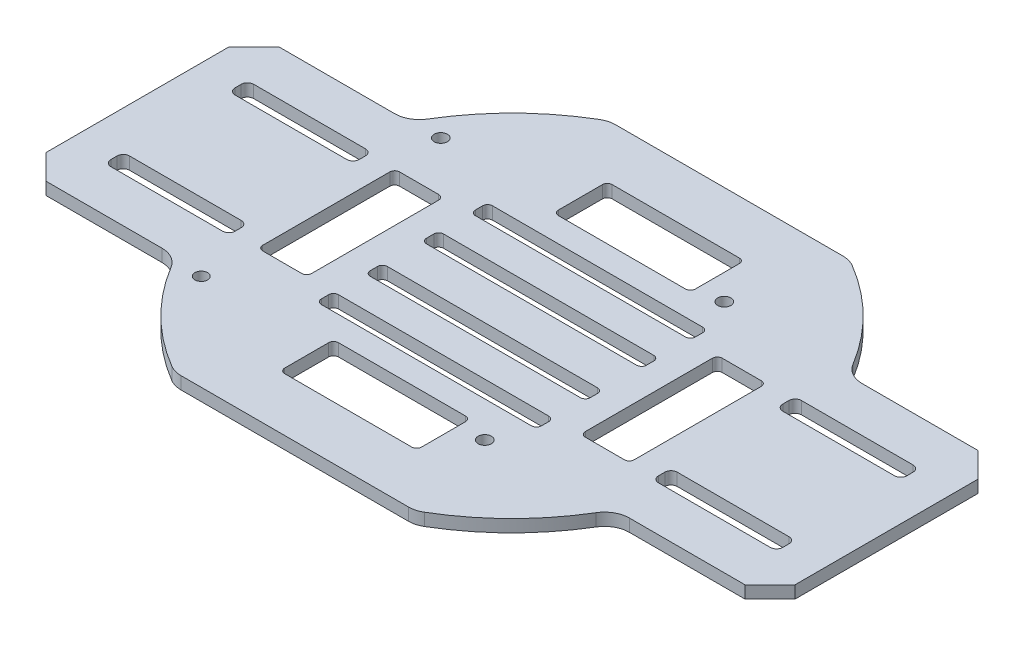
from build123d import *

# Parameters (mm, degrees)
BOSS_EXTRUDE1_DEPTH = 2.54
SKETCH3_W           = 28
SKETCH3_H           = 11
SKETCH3_W_2         = 10
SKETCH3_H_2         = 28
CUT_EXTRUDE_1_DEPTH = 10
CUT_EXTRUDE2_DEPTH  = 2.54
SKETCH_1_W          = 45
SKETCH_1_H          = 3.5
CUT_EXTRUDE_2_DEPTH = 2.54
FILLET_1_R          = 1
SKETCH_2_R          = 1.35
SKETCH_2_R_2        = 1.3
CUT_EXTRUDE_5_DEPTH = 2.54


with BuildPart() as part:
    # Sketch1 → Boss-Extrude1 (new body)
    with BuildSketch(Plane(origin=(0, 0, 0), x_dir=(1, 0, 0), z_dir=(0, 1, 0))):
        with BuildLine():
            Line((-23.244816627, 44.45), (23.244816627, 44.45))
            ThreePointArc((23.244816627, 44.45), (24.583514169, 44.270437622), (25.827574029, 43.744444444))
            ThreePointArc((25.827574029, 43.744444444), (35.740062311, 36.101079569), (43.482663438, 26.265909091))
            ThreePointArc((43.482663438, 26.265909091), (45.334600658, 24.468164919), (47.830929781, 23.8125))
            Line((47.830929781, 23.8125), (71.516875, 23.8125))
            Line((71.516875, 23.8125), (76.596875, 18.7325))
            Line((76.596875, 18.7325), (76.596875, -18.7325))
            Line((76.596875, -18.7325), (71.516875, -23.8125))
            Line((71.516875, -23.8125), (47.830929781, -23.8125))
            ThreePointArc((47.830929781, -23.8125), (45.334600658, -24.468164919), (43.482663438, -26.265909091))
            ThreePointArc((43.482663438, -26.265909091), (35.740062311, -36.101079569), (25.827574029, -43.744444444))
            ThreePointArc((25.827574029, -43.744444444), (24.583514169, -44.270437622), (23.244816627, -44.45))
            Line((23.244816627, -44.45), (-23.244816627, -44.45))
            ThreePointArc((-23.244816627, -44.45), (-24.583514169, -44.270437622), (-25.827574029, -43.744444444))
            ThreePointArc((-25.827574029, -43.744444444), (-35.740062311, -36.101079569), (-43.482663438, -26.265909091))
            ThreePointArc((-43.482663438, -26.265909091), (-45.334600658, -24.468164919), (-47.830929781, -23.8125))
            Line((-47.830929781, -23.8125), (-71.516875, -23.8125))
            Line((-71.516875, -23.8125), (-76.596875, -18.7325))
            Line((-76.596875, -18.7325), (-76.596875, 18.7325))
            Line((-76.596875, 18.7325), (-71.516875, 23.8125))
            Line((-71.516875, 23.8125), (-47.830929781, 23.8125))
            ThreePointArc((-47.830929781, 23.8125), (-45.334600658, 24.468164919), (-43.482663438, 26.265909091))
            ThreePointArc((-43.482663438, 26.265909091), (-35.740062311, 36.101079569), (-25.827574029, 43.744444444))
            ThreePointArc((-25.827574029, 43.744444444), (-24.583514169, 44.270437622), (-23.244816627, 44.45))
        make_face()
    extrude(amount=BOSS_EXTRUDE1_DEPTH)

    # Sketch3 → 切除-拉伸1 (cut)
    with BuildSketch(Plane(origin=(0, 2.54, 0), x_dir=(1, 0, 0), z_dir=(0, 1, 0))):
        with Locations((0, 28)):
            Rectangle(SKETCH3_W, SKETCH3_H)
        with Locations((0, -28)):
            Rectangle(SKETCH3_W, SKETCH3_H)
        with Locations((-33, 0)):
            Rectangle(SKETCH3_W_2, SKETCH3_H_2)
        with Locations((33, 0)):
            Rectangle(SKETCH3_W_2, SKETCH3_H_2)
    extrude(amount=-CUT_EXTRUDE_1_DEPTH, mode=Mode.SUBTRACT)

    # Sketch4 → Cut-Extrude2 (cut)
    with BuildSketch(Plane(origin=(0, 2.54, 0), x_dir=(1, 0, 0), z_dir=(0, 1, 0))):
        with BuildLine():
            Line((44.592875, 14.605), (67.452875, 14.605))
            ThreePointArc((67.452875, 14.605), (68.350900612, 14.233025612), (68.722875, 13.335))
            Line((68.722875, 13.335), (68.722875, 12.065))
            ThreePointArc((68.722875, 12.065), (68.350900612, 11.166974388), (67.452875, 10.795))
            Line((67.452875, 10.795), (44.592875, 10.795))
            ThreePointArc((44.592875, 10.795), (43.694849388, 11.166974388), (43.322875, 12.065))
            Line((43.322875, 12.065), (43.322875, 13.335))
            ThreePointArc((43.322875, 13.335), (43.694849388, 14.233025612), (44.592875, 14.605))
        make_face()
        with BuildLine():
            Line((68.722875, -13.335), (68.722875, -12.065))
            ThreePointArc((68.722875, -12.065), (68.350900612, -11.166974388), (67.452875, -10.795))
            Line((67.452875, -10.795), (44.592875, -10.795))
            ThreePointArc((44.592875, -10.795), (43.694849388, -11.166974388), (43.322875, -12.065))
            Line((43.322875, -12.065), (43.322875, -13.335))
            ThreePointArc((43.322875, -13.335), (43.694849388, -14.233025612), (44.592875, -14.605))
            Line((44.592875, -14.605), (67.452875, -14.605))
            ThreePointArc((67.452875, -14.605), (68.350900612, -14.233025612), (68.722875, -13.335))
        make_face()
        with BuildLine():
            Line((-44.592875, -14.605), (-67.452875, -14.605))
            ThreePointArc((-67.452875, -14.605), (-68.350900612, -14.233025612), (-68.722875, -13.335))
            Line((-68.722875, -13.335), (-68.722875, -12.065))
            ThreePointArc((-68.722875, -12.065), (-68.350900612, -11.166974388), (-67.452875, -10.795))
            Line((-67.452875, -10.795), (-44.592875, -10.795))
            ThreePointArc((-44.592875, -10.795), (-43.694849388, -11.166974388), (-43.322875, -12.065))
            Line((-43.322875, -12.065), (-43.322875, -13.335))
            ThreePointArc((-43.322875, -13.335), (-43.694849388, -14.233025612), (-44.592875, -14.605))
        make_face()
        with BuildLine():
            Line((-68.722875, 13.335), (-68.722875, 12.065))
            ThreePointArc((-68.722875, 12.065), (-68.350900612, 11.166974388), (-67.452875, 10.795))
            Line((-67.452875, 10.795), (-44.592875, 10.795))
            ThreePointArc((-44.592875, 10.795), (-43.694849388, 11.166974388), (-43.322875, 12.065))
            Line((-43.322875, 12.065), (-43.322875, 13.335))
            ThreePointArc((-43.322875, 13.335), (-43.694849388, 14.233025612), (-44.592875, 14.605))
            Line((-44.592875, 14.605), (-67.452875, 14.605))
            ThreePointArc((-67.452875, 14.605), (-68.350900612, 14.233025612), (-68.722875, 13.335))
        make_face()
    extrude(amount=-CUT_EXTRUDE2_DEPTH, mode=Mode.SUBTRACT)

    # 草图1 → 切除-拉伸2 (cut)
    with BuildSketch(Plane(origin=(0, 2.54, 0), x_dir=(1, 0, 0), z_dir=(0, 1, 0))):
        with Locations((0, 5.75)):
            Rectangle(SKETCH_1_W, SKETCH_1_H)
        with Locations((0, 15.75)):
            Rectangle(SKETCH_1_W, SKETCH_1_H)
        with Locations((0, -5.75)):
            Rectangle(SKETCH_1_W, SKETCH_1_H)
        with Locations((0, -15.75)):
            Rectangle(SKETCH_1_W, SKETCH_1_H)
    extrude(amount=-CUT_EXTRUDE_2_DEPTH, mode=Mode.SUBTRACT)

    # 圆角1
    fillet_1_edges = [part.edges().sort_by_distance(p)[0] for p in [
        (-28, 1.27, -14),
        (-28, 1.27, 14),
        (-38, 1.27, 14),
        (-38, 1.27, -14),
        (38, 1.27, 14),
        (28, 1.27, 14),
        (28, 1.27, -14),
        (38, 1.27, -14),
        (22.5, 1.27, 17.5),
        (22.5, 1.27, 14),
        (-22.5, 1.27, 14),
        (-22.5, 1.27, 17.5),
        (22.5, 1.27, -17.5),
        (-22.5, 1.27, -17.5),
        (-22.5, 1.27, -14),
        (22.5, 1.27, -14),
        (22.5, 1.27, 7.5),
        (22.5, 1.27, 4),
        (-22.5, 1.27, 4),
        (-22.5, 1.27, 7.5),
        (-22.5, 1.27, -7.5),
        (-22.5, 1.27, -4),
        (22.5, 1.27, -4),
        (22.5, 1.27, -7.5),
        (14, 1.27, -33.5),
        (14, 1.27, -22.5),
        (-14, 1.27, -22.5),
        (-14, 1.27, -33.5),
        (14, 1.27, 33.5),
        (-14, 1.27, 33.5),
        (-14, 1.27, 22.5),
        (14, 1.27, 22.5),
    ]]
    fillet(fillet_1_edges, radius=FILLET_1_R)

    # 草图2 → 切除-拉伸5 (cut)
    with BuildSketch(Plane.XZ):
        with Locations((19.207738721, -24.223015039)):
            Circle(SKETCH_2_R)
        with Locations((19.207738721, 24.776984961)):
            Circle(SKETCH_2_R)
        with Locations((-38.792261279, -24.223015039)):
            Circle(SKETCH_2_R)
        with Locations((-38.792261279, 24.776984961)):
            Circle(SKETCH_2_R_2)
    extrude(amount=-CUT_EXTRUDE_5_DEPTH, mode=Mode.SUBTRACT)


solid = part.part
